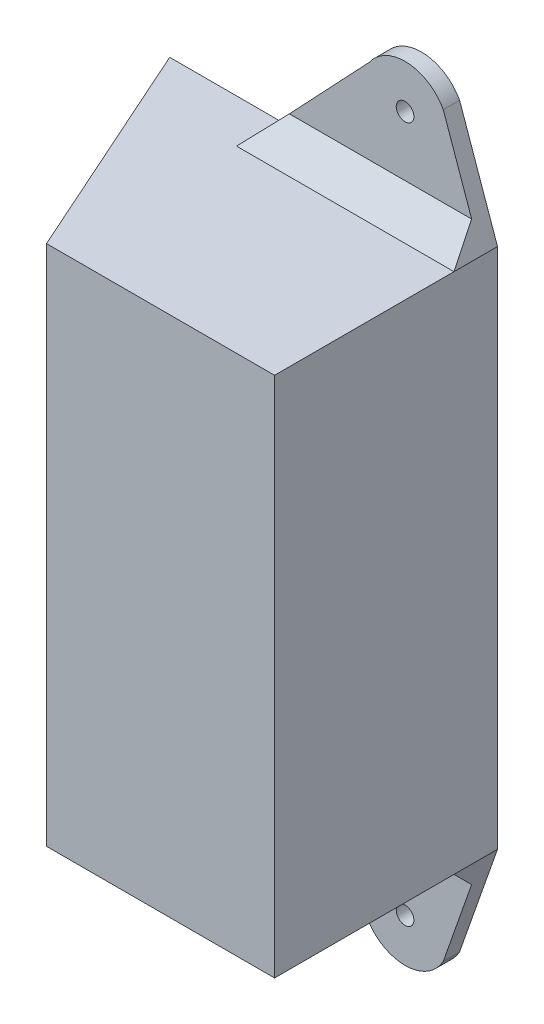
from build123d import *

# Parameters (mm, degrees)
SALIENTE_EXTRUIR1_DEPTH = 38
CROQUIS2_R              = 1.625
SALIENTE_EXTRUIR2_DEPTH = 3
CHAFL_N1_SIZE           = 5
SALIENTE_EXTRUIR3_DEPTH = 3
SALIENTE_EXTRUIR4_DEPTH = 3
CROQUIS6_W              = 40
CROQUIS6_H              = 96
SALIENTE_EXTRUIR5_DEPTH = 3
SALIENTE_EXTRUIR6_DEPTH = 96
SALIENTE_EXTRUIR7_DEPTH = 2


with BuildPart() as part:
    # Croquis1 → Saliente-Extruir1 (new body)
    with BuildSketch(Plane.XY):
        Polygon((0, 45), (37, 45), (37, -45), (0, -45), (0, -48), (40, -48), (40, 48), (0, 48), align=None)
    extrude(amount=SALIENTE_EXTRUIR1_DEPTH)

    # Croquis2 → Saliente-Extruir2 (add)
    with BuildSketch(Plane(origin=(0, 0, 0), x_dir=(-1, 0, 0), z_dir=(0, 0, -1))):
        with BuildLine():
            Line((-40, -48), (-33.026334459, -67.824999879))
            ThreePointArc((-33.026334459, -67.824999879), (-26.445010121, -71.987613285), (-19.442030485, -68.58181578))
            Line((-19.442030485, -68.58181578), (0, -48))
            Line((0, -48), (-40, -48))
        make_face()
        with Locations((-26, -64)):
            Circle(CROQUIS2_R, mode=Mode.SUBTRACT)
        with BuildLine():
            Line((-40, 48), (0, 48))
            Line((0, 48), (-19.442030485, 68.58181578))
            ThreePointArc((-19.442030485, 68.58181578), (-26.445010121, 71.987613285), (-33.026334459, 67.824999879))
            Line((-33.026334459, 67.824999879), (-40, 48))
        make_face()
        with Locations((-26, 64)):
            Circle(CROQUIS2_R, mode=Mode.SUBTRACT)
    extrude(amount=-SALIENTE_EXTRUIR2_DEPTH)

    # Chaflán1
    chafl_n1_edges = [part.edges().sort_by_distance(p)[0] for p in [
        (20, -48, 3),
        (20, 48, 3),
    ]]
    chamfer(chafl_n1_edges, length=CHAFL_N1_SIZE)

    # Croquis3 → Saliente-Extruir3 (add)
    with BuildSketch(Plane.XZ.offset(48)):
        Polygon((0, 38), (-17, 0), (0, 0), align=None)
    extrude(amount=-SALIENTE_EXTRUIR3_DEPTH)

    # Croquis4 → Saliente-Extruir4 (add)
    with BuildSketch(Plane(origin=(0, 48, 0), x_dir=(1, 0, 0), z_dir=(0, 1, 0))):
        Polygon((0, 0), (0, -38), (-17, 0), align=None)
    extrude(amount=-SALIENTE_EXTRUIR4_DEPTH)

    # Croquis6 → Saliente-Extruir5 (add)
    with BuildSketch(Plane.XY.offset(38)):
        with Locations((20, 0)):
            Rectangle(CROQUIS6_W, CROQUIS6_H)
    extrude(amount=SALIENTE_EXTRUIR5_DEPTH)

    # Croquis7 → Saliente-Extruir6 (add)
    with BuildSketch(Plane.XZ.offset(48)):
        Polygon((-17, 0), (0, 38), (0, 41), (-1.944419731, 41), (-20.286524994, 0), align=None)
    extrude(amount=-SALIENTE_EXTRUIR6_DEPTH)

    # Croquis8 → Saliente-Extruir7 (add)
    with BuildSketch(Plane(origin=(-16.903486493, 0, 7.562086062), x_dir=(0.40836606, 0, 0.912818252), z_dir=(-0.912818252, 0, 0.40836606))):
        with BuildLine():
            add(Edge.make_bspline(
                [(5.965671716, 30.36328125), (5.969777422, 30.634302022), (5.97778628, 31.162972825), (6.051447483, 31.933692823), (6.159339503, 32.662226364), (6.326924559, 33.343984113), (6.529341591, 33.984579111), (6.79151938, 34.575666339), (7.088726166, 35.129018553), (7.330384134, 35.463352831), (7.450046716, 35.62890625)],
                knots=[0, 0, 0, 0, 0.000812838, 0.001585575, 0.002320915, 0.003020123, 0.003689655, 0.004333381, 0.004957513, 0.005569711, 0.005569711, 0.005569711, 0.005569711], degree=3))
            add(Edge.make_bspline(
                [(7.450046716, 35.62890625), (7.553673427, 35.756762143), (7.754719282, 36.00481496), (8.078174582, 36.340898549), (8.419904084, 36.61842414), (8.771347852, 36.848802777), (9.13456118, 37.031738976), (9.513179133, 37.154081432), (9.900673914, 37.239339417), (10.164422368, 37.246421297), (10.297702966, 37.25)],
                knots=[0, 0, 0, 0, 0.000493642, 0.000957714, 0.001396364, 0.001811328, 0.002216619, 0.002611904, 0.003002607, 0.003401733, 0.003401733, 0.003401733, 0.003401733], degree=3))
            add(Edge.make_bspline(
                [(10.297702966, 37.25), (10.429822742, 37.244586132), (10.687522929, 37.23402636), (11.056297545, 37.134519745), (11.387218266, 36.966346565), (11.677456504, 36.73904813), (11.920195351, 36.455945202), (12.094779911, 36.1153008), (12.197073919, 35.723276709), (12.209281684, 35.44594681), (12.215671716, 35.30078125)],
                knots=[0, 0, 0, 0, 0.000395767, 0.000771945, 0.00113531, 0.001502581, 0.001871199, 0.002245079, 0.002641135, 0.003076151, 0.003076151, 0.003076151, 0.003076151], degree=3))
            add(Edge.make_bspline(
                [(12.215671716, 35.30078125), (12.211834834, 35.201557757), (12.204352359, 35.008057567), (12.148733947, 34.729162915), (12.058811627, 34.470218823), (11.928050321, 34.232525347), (11.757435691, 34.018106537), (11.555647016, 33.819389361), (11.315754931, 33.641544695), (11.133857418, 33.548213979), (11.039890466, 33.5)],
                knots=[0, 0, 0, 0, 0.000297517, 0.000580201, 0.000849534, 0.001117019, 0.00138973, 0.00166872, 0.001964823, 0.002281253, 0.002281253, 0.002281253, 0.002281253], degree=3))
            add(Edge.make_bspline(
                [(11.039890466, 33.5), (10.91436369, 33.434443546), (10.663995614, 33.303688628), (10.34327864, 33.0213451), (10.065057019, 32.691686878), (9.844623673, 32.298302696), (9.674362764, 31.849036212), (9.551043095, 31.342749802), (9.476603513, 30.779551596), (9.469425304, 30.385659352), (9.465671716, 30.1796875)],
                knots=[0, 0, 0, 0, 0.000423463, 0.000844614, 0.001271737, 0.001712642, 0.002189973, 0.002709151, 0.003272654, 0.003890286, 0.003890286, 0.003890286, 0.003890286], degree=3))
            add(Edge.make_bspline(
                [(9.465671716, 30.1796875), (9.468590461, 29.995985609), (9.474416706, 29.629289488), (9.524035202, 29.083109154), (9.597397863, 28.540445487), (9.702410238, 28.002898303), (9.840791609, 27.468582346), (10.007658096, 26.938704675), (10.207735792, 26.413821778), (10.361159091, 26.07091354), (10.438327966, 25.8984375)],
                knots=[0, 0, 0, 0, 0.000551003, 0.001099883, 0.001644031, 0.002193314, 0.002741875, 0.003299046, 0.003859113, 0.004425896, 0.004425896, 0.004425896, 0.004425896], degree=3))
            add(Edge.make_bspline(
                [(10.438327966, 25.8984375), (10.5206725, 25.729254519), (10.677123914, 25.407813433), (10.934622805, 24.969854511), (11.194905283, 24.5952256), (11.470695314, 24.295443596), (11.742961267, 24.047573089), (12.031337759, 23.877105944), (12.327220813, 23.772883566), (12.527408766, 23.757542292), (12.625827966, 23.75)],
                knots=[0, 0, 0, 0, 0.00056426, 0.001072073, 0.001522987, 0.001929481, 0.002292174, 0.002623123, 0.002928236, 0.003223307, 0.003223307, 0.003223307, 0.003223307], degree=3))
            add(Edge.make_bspline(
                [(12.625827966, 23.75), (12.756404433, 23.752620818), (13.007710327, 23.757664814), (13.365679792, 23.827553873), (13.692820878, 23.9306952), (13.982591123, 24.084324753), (14.238889739, 24.278515986), (14.455041332, 24.51866116), (14.643147362, 24.797021755), (14.729765645, 25.008527307), (14.774265466, 25.1171875)],
                knots=[0, 0, 0, 0, 0.000391113, 0.000752731, 0.001089961, 0.001416711, 0.00173157, 0.002049516, 0.002382121, 0.002733532, 0.002733532, 0.002733532, 0.002733532], degree=3))
            add(Edge.make_bspline(
                [(14.774265466, 25.1171875), (14.805970758, 25.207825433), (14.875669416, 25.40707741), (14.948166421, 25.74581325), (15.01932726, 26.142869369), (15.075397293, 26.602144038), (15.125781228, 27.121830616), (15.168663722, 27.702657595), (15.199664175, 28.344785617), (15.210174324, 28.792936129), (15.215671716, 29.02734375)],
                knots=[0, 0, 0, 0, 0.000287819, 0.000632722, 0.001037315, 0.001498087, 0.002020095, 0.00260371, 0.003245097, 0.003948493, 0.003948493, 0.003948493, 0.003948493], degree=3))
            add(Edge.make_bspline(
                [(15.215671716, 29.02734375), (15.231293463, 29.397904388), (15.261815507, 30.121912251), (15.438500027, 31.174693804), (15.685865109, 32.173488066), (15.938809758, 32.798025083), (16.063327966, 33.10546875)],
                knots=[0, 0, 0, 0, 0.001111601, 0.002171865, 0.003197001, 0.00419094, 0.00419094, 0.00419094, 0.00419094], degree=3))
            add(Edge.make_bspline(
                [(16.063327966, 33.10546875), (16.153977971, 33.297966849), (16.327812467, 33.667109798), (16.648641052, 34.161530677), (16.989330346, 34.586816264), (17.370195276, 34.92638519), (17.776248945, 35.195326159), (18.216003979, 35.37976083), (18.685377302, 35.490563556), (19.008023177, 35.496811184), (19.172702966, 35.5)],
                knots=[0, 0, 0, 0, 0.000637629, 0.001222745, 0.001763913, 0.00226738, 0.002747356, 0.003218217, 0.003691067, 0.004184013, 0.004184013, 0.004184013, 0.004184013], degree=3))
            add(Edge.make_bspline(
                [(19.172702966, 35.5), (19.383133092, 35.489330289), (19.804392211, 35.467970642), (20.425503556, 35.322250941), (21.036092544, 35.109044929), (21.630099528, 34.803685744), (22.206451183, 34.410364119), (22.773711286, 33.940601473), (23.325255341, 33.385998264), (23.851017267, 32.758308671), (24.347088649, 32.087714846), (24.775573283, 31.38050143), (25.147202655, 30.662268595), (25.443423634, 29.922137994), (25.681450327, 29.168237885), (25.84231204, 28.393291847), (25.950175353, 27.603309591), (25.96048539, 27.069371583), (25.965671716, 26.80078125)],
                knots=[0, 0, 0, 0, 0.000630953, 0.001263102, 0.001905559, 0.002567665, 0.003259965, 0.003995181, 0.004774103, 0.005602863, 0.006449799, 0.007273824, 0.008080935, 0.008873047, 0.009662544, 0.01044937, 0.011244942, 0.012050236, 0.012050236, 0.012050236, 0.012050236], degree=3))
            add(Edge.make_bspline(
                [(25.965671716, 26.80078125), (25.958390342, 26.572535522), (25.94292304, 26.087689435), (25.822968219, 25.325926481), (25.645291601, 24.487667488), (25.476274874, 23.911725421), (25.387546716, 23.609375)],
                knots=[0, 0, 0, 0, 0.000684497, 0.001454028, 0.00230906, 0.003253969, 0.003253969, 0.003253969, 0.003253969], degree=3))
            add(Edge.make_bspline(
                [(25.387546716, 23.609375), (25.328971324, 23.423538611), (25.218910095, 23.074358163), (25.024477779, 22.595860821), (24.834222475, 22.185269169), (24.627208362, 21.851830138), (24.417624911, 21.587645796), (24.198917313, 21.396480915), (23.968618102, 21.270664328), (23.805545788, 21.256695034), (23.727390466, 21.25)],
                knots=[0, 0, 0, 0, 0.000584282, 0.001097846, 0.001548607, 0.001939896, 0.002273005, 0.002555608, 0.002808913, 0.003042048, 0.003042048, 0.003042048, 0.003042048], degree=3))
            add(Edge.make_bspline(
                [(23.727390466, 21.25), (23.618730778, 21.256397837), (23.404462582, 21.26901386), (23.09210073, 21.358611728), (22.799926472, 21.50743), (22.629984532, 21.647640693), (22.543796716, 21.71875)],
                knots=[0, 0, 0, 0, 0.000325721, 0.000642296, 0.000967244, 0.001301633, 0.001301633, 0.001301633, 0.001301633], degree=3))
            add(Edge.make_bspline(
                [(22.543796716, 21.71875), (22.454451619, 21.808809898), (22.279307214, 21.985355538), (22.097947988, 22.314141585), (21.983039457, 22.675923308), (21.97156254, 22.931380168), (21.965671716, 23.0625)],
                knots=[0, 0, 0, 0, 0.000378906, 0.000742775, 0.00111469, 0.001506894, 0.001506894, 0.001506894, 0.001506894], degree=3))
            add(Edge.make_bspline(
                [(21.965671716, 23.0625), (21.969341393, 23.177191653), (21.977537807, 23.433361374), (22.029164939, 23.854238637), (22.107188362, 24.350626213), (22.216203362, 24.895732972), (22.323600417, 25.441142593), (22.402600073, 25.939978671), (22.453797135, 26.363528423), (22.461996372, 26.622290166), (22.465671716, 26.73828125)],
                knots=[0, 0, 0, 0, 0.000344105, 0.000768576, 0.001270784, 0.00185149, 0.002436032, 0.00293824, 0.003366594, 0.003714601, 0.003714601, 0.003714601, 0.003714601], degree=3))
            add(Edge.make_bspline(
                [(22.465671716, 26.73828125), (22.454620069, 27.016384253), (22.432662659, 27.568919228), (22.27226995, 28.38403688), (22.026719165, 29.180064167), (21.783534273, 29.681101901), (21.660984216, 29.93359375)],
                knots=[0, 0, 0, 0, 0.000833827, 0.001656646, 0.002484366, 0.003325226, 0.003325226, 0.003325226, 0.003325226], degree=3))
            add(Edge.make_bspline(
                [(21.660984216, 29.93359375), (21.595094092, 30.057017109), (21.469831212, 30.291655696), (21.262214793, 30.611719685), (21.046920458, 30.880550624), (20.833393022, 31.108616174), (20.609413616, 31.283374531), (20.379404891, 31.406298498), (20.145493362, 31.487128452), (19.98581651, 31.495749071), (19.907077966, 31.5)],
                knots=[0, 0, 0, 0, 0.000419627, 0.000797747, 0.001142428, 0.001451836, 0.001733113, 0.001990007, 0.002232131, 0.002467675, 0.002467675, 0.002467675, 0.002467675], degree=3))
            add(Edge.make_bspline(
                [(19.907077966, 31.5), (19.828057076, 31.493900957), (19.671210511, 31.48179512), (19.449468336, 31.386073433), (19.252477758, 31.230410484), (19.080097438, 31.015216645), (18.938410873, 30.738529851), (18.81200715, 30.407943228), (18.71868149, 30.014680862), (18.673342568, 29.732096729), (18.649265466, 29.58203125)],
                knots=[0, 0, 0, 0, 0.000236449, 0.000469322, 0.000711541, 0.000983636, 0.001289473, 0.001640601, 0.002043248, 0.00249921, 0.00249921, 0.00249921, 0.00249921], degree=3))
            add(Edge.make_bspline(
                [(18.649265466, 29.58203125), (18.617725092, 29.022151322), (18.554794602, 27.905058726), (18.495332019, 26.787776171), (18.465671716, 26.23046875)],
                knots=[0, 0, 0, 0, 0.001682302, 0.003356589, 0.003356589, 0.003356589, 0.003356589], degree=3))
            add(Edge.make_bspline(
                [(18.465671716, 26.23046875), (18.444171242, 25.993087481), (18.402176228, 25.529431205), (18.286299144, 24.8566621), (18.139773879, 24.220311391), (17.952672522, 23.623646334), (17.729703599, 23.063751948), (17.466583581, 22.542669129), (17.169354052, 22.056142644), (16.936142973, 21.762158702), (16.821140466, 21.6171875)],
                knots=[0, 0, 0, 0, 0.000714801, 0.001396159, 0.002046148, 0.002672526, 0.003270233, 0.003851963, 0.004422128, 0.004976829, 0.004976829, 0.004976829, 0.004976829], degree=3))
            add(Edge.make_bspline(
                [(16.821140466, 21.6171875), (16.686637362, 21.467781616), (16.420244223, 21.171872441), (15.961798381, 20.793742772), (15.470565281, 20.468772898), (14.937920626, 20.207594973), (14.369431498, 19.997185357), (13.760023308, 19.857517929), (13.115811875, 19.762220663), (12.673072078, 19.754141217), (12.446140466, 19.75)],
                knots=[0, 0, 0, 0, 0.000602374, 0.001193045, 0.001777013, 0.00236573, 0.002968787, 0.003591268, 0.004238162, 0.004918399, 0.004918399, 0.004918399, 0.004918399], degree=3))
            add(Edge.make_bspline(
                [(12.446140466, 19.75), (12.306746719, 19.753436109), (12.031206821, 19.760228274), (11.624135507, 19.801076628), (11.230858099, 19.883004937), (10.848145019, 19.985377378), (10.480768164, 20.124281924), (10.124698141, 20.287671415), (9.786302184, 20.489613804), (9.45567061, 20.715843981), (9.140389702, 20.975533399), (8.833635377, 21.260030292), (8.544779452, 21.579420755), (8.266628538, 21.926649016), (8.005245991, 22.307899596), (7.756502019, 22.718194091), (7.516191679, 23.156668293), (7.371594652, 23.464027605), (7.297702966, 23.62109375)],
                knots=[0, 0, 0, 0, 0.000418261, 0.000826777, 0.001225138, 0.001622213, 0.002014028, 0.002401988, 0.002795919, 0.003194663, 0.003602805, 0.004020116, 0.004448684, 0.004893413, 0.00535392, 0.005834262, 0.006332443, 0.006853074, 0.006853074, 0.006853074, 0.006853074], degree=3))
            add(Edge.make_bspline(
                [(7.297702966, 23.62109375), (7.190208386, 23.86978415), (6.973863715, 24.370300943), (6.707918069, 25.151079656), (6.476275425, 25.954932073), (6.288523274, 26.785765629), (6.145459714, 27.642872024), (6.039610494, 28.526489434), (5.975839384, 29.436549006), (5.969087149, 30.051981534), (5.965671716, 30.36328125)],
                knots=[0, 0, 0, 0, 0.0008125, 0.001635246, 0.002472287, 0.003321373, 0.004188965, 0.005078055, 0.005990355, 0.006924153, 0.006924153, 0.006924153, 0.006924153], degree=3))
        make_face()
        with BuildLine():
            add(Edge.make_bspline(
                [(6.215671716, 2.88671875), (6.226597424, 2.975217121), (6.249586424, 3.161428295), (6.385566207, 3.431290004), (6.596790417, 3.695275544), (6.880472038, 3.95992956), (7.242105085, 4.219474387), (7.674209431, 4.486764788), (8.186421673, 4.749368309), (8.558506826, 4.913461698), (8.754734216, 5)],
                knots=[0, 0, 0, 0, 0.000265883, 0.00055945, 0.000890746, 0.001277602, 0.001719026, 0.002224187, 0.00280074, 0.003444074, 0.003444074, 0.003444074, 0.003444074], degree=3))
            add(Edge.make_bspline(
                [(8.754734216, 5), (9.032127533, 5.119072409), (9.601768262, 5.363593419), (10.502807764, 5.677851461), (11.46039743, 5.978794371), (12.124921619, 6.147742799), (12.465671716, 6.234375)],
                knots=[0, 0, 0, 0, 0.000905349, 0.001859178, 0.002861198, 0.003915755, 0.003915755, 0.003915755, 0.003915755], degree=3))
            add(Edge.make_bspline(
                [(12.465671716, 6.234375), (12.456687675, 6.32032522), (12.437493846, 6.503952369), (12.403892549, 6.797749307), (12.378597431, 7.128830166), (12.352165197, 7.497470419), (12.318074208, 7.903345658), (12.294389465, 8.349079842), (12.25996748, 8.831801529), (12.243646437, 9.166626545), (12.235202966, 9.33984375)],
                knots=[0, 0, 0, 0, 0.000259258, 0.000553889, 0.000887044, 0.001255249, 0.001662699, 0.00210885, 0.002594232, 0.003114482, 0.003114482, 0.003114482, 0.003114482], degree=3))
            add(Edge.make_bspline(
                [(12.235202966, 9.33984375), (12.217001677, 9.657644628), (12.182816847, 10.254523736), (12.115125551, 11.09037255), (12.048326871, 11.808381671), (11.991508361, 12.246218375), (11.965671716, 12.4453125)],
                knots=[0, 0, 0, 0, 0.000954924, 0.001793495, 0.002515676, 0.003117923, 0.003117923, 0.003117923, 0.003117923], degree=3))
            add(Edge.make_bspline(
                [(11.965671716, 12.4453125), (11.826012935, 12.497852353), (11.529501354, 12.609400477), (11.065911535, 12.804672276), (10.549014986, 13.017758366), (9.983144028, 13.261268157), (9.365707131, 13.528669072), (8.703004189, 13.832820156), (7.987691705, 14.154449017), (7.496683741, 14.382290696), (7.243015466, 14.5)],
                knots=[0, 0, 0, 0, 0.000447602, 0.000950311, 0.001508905, 0.002124917, 0.002798391, 0.003527396, 0.004312329, 0.005151264, 0.005151264, 0.005151264, 0.005151264], degree=3))
            add(Edge.make_bspline(
                [(7.243015466, 14.5), (7.16084071, 14.548674139), (7.002096897, 14.642702024), (6.794702375, 14.813810954), (6.6151975, 14.993820184), (6.470329707, 15.190552204), (6.35462851, 15.400232267), (6.272047844, 15.623819874), (6.22420476, 15.862550284), (6.218560156, 16.025824679), (6.215671716, 16.109375)],
                knots=[0, 0, 0, 0, 0.000286118, 0.000552718, 0.000804087, 0.001047061, 0.001283058, 0.001520344, 0.001759361, 0.002009849, 0.002009849, 0.002009849, 0.002009849], degree=3))
            add(Edge.make_bspline(
                [(6.215671716, 16.109375), (6.221481612, 16.228503463), (6.232970077, 16.464067587), (6.331268012, 16.806197336), (6.491562445, 17.127887179), (6.706782468, 17.423407479), (6.969455777, 17.68080029), (7.278638422, 17.865819626), (7.622847275, 17.983188354), (7.864438416, 17.994277534), (7.989109216, 18)],
                knots=[0, 0, 0, 0, 0.00035684, 0.000705613, 0.001058497, 0.001430412, 0.00179787, 0.002153596, 0.002503178, 0.002875934, 0.002875934, 0.002875934, 0.002875934], degree=3))
            add(Edge.make_bspline(
                [(7.989109216, 18), (8.021754972, 17.998128777), (8.096780084, 17.99382841), (8.220147283, 17.96713291), (8.369288315, 17.933299323), (8.542124509, 17.88044471), (8.741422403, 17.814118085), (8.966029364, 17.731427037), (9.216916889, 17.638639685), (9.491095352, 17.527702905), (9.792030163, 17.403021972), (10.118048768, 17.26180796), (10.471661193, 17.111444336), (10.845470059, 16.936585156), (11.247946193, 16.753309675), (11.678636253, 16.560354489), (12.129607322, 16.343470569), (12.439561818, 16.196466749), (12.598484216, 16.12109375)],
                knots=[0, 0, 0, 0, 9.7968e-05, 0.000225147, 0.00037769, 0.00055691, 0.000766905, 0.001007861, 0.001274861, 0.001569362, 0.001895084, 0.002252073, 0.002635224, 0.003047736, 0.003489988, 0.003961982, 0.00446346, 0.004991137, 0.004991137, 0.004991137, 0.004991137], degree=3))
            add(Edge.make_bspline(
                [(12.598484216, 16.12109375), (12.730914756, 16.172734623), (12.979981057, 16.269857246), (13.246917507, 16.27495603), (13.371921716, 16.27734375)],
                knots=[0, 0, 0, 0, 0.000422489, 0.000794589, 0.000794589, 0.000794589, 0.000794589], degree=3))
            add(Edge.make_bspline(
                [(13.371921716, 16.27734375), (13.424706588, 16.269503685), (13.530181082, 16.253837702), (13.679176138, 16.182419458), (13.8171152, 16.076801407), (13.952456261, 15.940656609), (14.066291751, 15.758520764), (14.180253107, 15.54797869), (14.285978145, 15.301178645), (14.342317847, 15.121668109), (14.371921716, 15.02734375)],
                knots=[0, 0, 0, 0, 0.000159344, 0.000318401, 0.000488715, 0.000679323, 0.000890586, 0.001130017, 0.001397759, 0.001694222, 0.001694222, 0.001694222, 0.001694222], degree=3))
            add(Edge.make_bspline(
                [(14.371921716, 15.02734375), (14.923663023, 14.71651878), (16.042378716, 14.086287243), (17.725996316, 13.096246575), (19.440012895, 12.054894345), (20.585238885, 11.331159343), (21.164890466, 10.96484375)],
                knots=[0, 0, 0, 0, 0.001899775, 0.003852002, 0.005859107, 0.00791617, 0.00791617, 0.00791617, 0.00791617], degree=3))
            add(Edge.make_bspline(
                [(21.164890466, 10.96484375), (21.369749384, 10.835306896), (21.766911784, 10.58417227), (22.337087326, 10.208157793), (22.867411561, 9.850677187), (23.365320652, 9.52251155), (23.81737749, 9.203865946), (24.23350764, 8.908446083), (24.606242845, 8.626619244), (24.943328899, 8.369005397), (25.242089127, 8.132944219), (25.495533646, 7.907757531), (25.713945074, 7.708026944), (25.892682018, 7.525712686), (26.034626119, 7.364913027), (26.134732002, 7.218634844), (26.199583859, 7.090937491), (26.210826145, 7.008281888), (26.215671716, 6.97265625)],
                knots=[0, 0, 0, 0, 0.000727119, 0.001409674, 0.00204888, 0.002645834, 0.003198496, 0.003707988, 0.004176738, 0.004600202, 0.004980876, 0.00531858, 0.005617095, 0.005868465, 0.006084548, 0.006258978, 0.006400576, 0.006507838, 0.006507838, 0.006507838, 0.006507838], degree=3))
            add(Edge.make_bspline(
                [(26.215671716, 6.97265625), (26.210861665, 6.85367274), (26.201590584, 6.624339221), (26.1172731, 6.294659081), (25.973927066, 5.999382048), (25.779654454, 5.730128721), (25.522833839, 5.500926288), (25.219154489, 5.293521651), (24.854175051, 5.127871763), (24.589058257, 5.043985163), (24.450046716, 5)],
                knots=[0, 0, 0, 0, 0.000356519, 0.000687169, 0.001012139, 0.001336382, 0.001676405, 0.00203935, 0.002436041, 0.002873332, 0.002873332, 0.002873332, 0.002873332], degree=3))
            add(Edge.make_bspline(
                [(24.450046716, 5), (24.325002369, 4.97679426), (24.05910302, 4.927448638), (23.638988805, 4.844328496), (23.172363366, 4.755640824), (22.662462938, 4.652752169), (22.107179751, 4.545066465), (21.510135084, 4.422220365), (20.867725015, 4.294402175), (20.425255243, 4.203381377), (20.196140466, 4.15625)],
                knots=[0, 0, 0, 0, 0.000381535, 0.000811311, 0.001284758, 0.001806458, 0.002371826, 0.002981626, 0.003635092, 0.004336827, 0.004336827, 0.004336827, 0.004336827], degree=3))
            add(Edge.make_bspline(
                [(20.196140466, 4.15625), (19.871959496, 4.085767146), (19.211867172, 3.942251037), (18.204108402, 3.726534371), (17.165086534, 3.488701376), (16.088997115, 3.247743716), (14.978201905, 2.994318649), (13.833655018, 2.728725154), (12.655501682, 2.450373874), (11.858869548, 2.260548162), (11.453952966, 2.1640625)],
                knots=[0, 0, 0, 0, 0.000995266, 0.002026546, 0.003091714, 0.004192895, 0.005334764, 0.006509714, 0.007717762, 0.008966523, 0.008966523, 0.008966523, 0.008966523], degree=3))
            add(Edge.make_bspline(
                [(11.453952966, 2.1640625), (11.417395542, 2.15397032), (11.333199529, 2.130726853), (11.192905378, 2.082489364), (11.021977963, 2.020841104), (10.819926531, 1.939860605), (10.585360673, 1.84793249), (10.317159347, 1.742948651), (10.021353609, 1.61659301), (9.813314082, 1.527370675), (9.703952966, 1.48046875)],
                knots=[0, 0, 0, 0, 0.000113752, 0.000261983, 0.000444869, 0.000658859, 0.00091492, 0.001200717, 0.001522835, 0.001879824, 0.001879824, 0.001879824, 0.001879824], degree=3))
            add(Edge.make_bspline(
                [(9.703952966, 1.48046875), (9.526483136, 1.407607138), (9.199612309, 1.273407789), (8.735027356, 1.123805994), (8.342109035, 1.024983769), (8.100189095, 1.007670153), (7.993015466, 1)],
                knots=[0, 0, 0, 0, 0.000575228, 0.001059477, 0.001464108, 0.001785942, 0.001785942, 0.001785942, 0.001785942], degree=3))
            add(Edge.make_bspline(
                [(7.993015466, 1), (7.869752312, 1.006143318), (7.62718787, 1.018232499), (7.281405928, 1.132548801), (6.967454441, 1.318128697), (6.696963992, 1.569651701), (6.473623904, 1.864633737), (6.316491338, 2.188614661), (6.219271283, 2.532101617), (6.216880925, 2.767591613), (6.215671716, 2.88671875)],
                knots=[0, 0, 0, 0, 0.000368867, 0.000725877, 0.001079603, 0.001455619, 0.001826713, 0.002183103, 0.002530847, 0.002886852, 0.002886852, 0.002886852, 0.002886852], degree=3))
        make_face()
        with BuildLine():
            add(Edge.make_bspline(
                [(19.895359216, 7.8984375), (19.745605766, 7.988258362), (19.433076827, 8.175710596), (18.945033459, 8.469071988), (18.417052175, 8.783578064), (17.854663916, 9.130503853), (17.249470086, 9.496002157), (16.605799343, 9.885899979), (15.923765286, 10.301690692), (15.456530903, 10.587196724), (15.215671716, 10.734375)],
                knots=[0, 0, 0, 0, 0.000523875, 0.001093303, 0.001708287, 0.002367506, 0.003075616, 0.003829279, 0.004625158, 0.005471958, 0.005471958, 0.005471958, 0.005471958], degree=3))
            add(Edge.make_bspline(
                [(15.215671716, 10.734375), (15.230375772, 10.621145338), (15.263115846, 10.369027996), (15.308106658, 9.94874934), (15.334110884, 9.445354944), (15.353621863, 9.082016775), (15.364109216, 8.88671875)],
                knots=[0, 0, 0, 0, 0.000342549, 0.000762721, 0.001267595, 0.001854366, 0.001854366, 0.001854366, 0.001854366], degree=3))
            add(Edge.make_bspline(
                [(15.364109216, 8.88671875), (15.369241314, 8.768226057), (15.378998972, 8.542935892), (15.394051559, 8.222588352), (15.411360667, 7.936282975), (15.421561952, 7.683536105), (15.433617637, 7.464799956), (15.444485089, 7.281130774), (15.457625224, 7.131588181), (15.463209354, 7.042979075), (15.465671716, 7.00390625)],
                knots=[0, 0, 0, 0, 0.000355812, 0.000676505, 0.000962089, 0.001216266, 0.00143533, 0.001619297, 0.001768196, 0.001885644, 0.001885644, 0.001885644, 0.001885644], degree=3))
            add(Edge.make_bspline(
                [(15.465671716, 7.00390625), (15.612758382, 7.032804712), (15.917210356, 7.092621105), (16.392023049, 7.180663408), (16.898096232, 7.283211398), (17.435454526, 7.393254039), (18.005378216, 7.504656446), (18.605729873, 7.632970732), (19.241210094, 7.757857601), (19.674142595, 7.850896948), (19.895359216, 7.8984375)],
                knots=[0, 0, 0, 0, 0.000449694, 0.000930813, 0.001448683, 0.001998729, 0.002576352, 0.003190765, 0.003840401, 0.00451919, 0.00451919, 0.00451919, 0.00451919], degree=3))
        make_face(mode=Mode.SUBTRACT)
        with BuildLine():
            add(Edge.make_bspline(
                [(17.160984216, -7.3046875), (16.973520929, -7.255069257), (16.575400345, -7.149693722), (15.945390165, -6.98612304), (15.247129631, -6.810366956), (14.481497803, -6.61898635), (13.648432512, -6.412151192), (12.747055272, -6.193457667), (11.779523137, -5.959431869), (11.111511151, -5.798152029), (10.766452966, -5.71484375)],
                knots=[0, 0, 0, 0, 0.000581756, 0.00123549, 0.001952678, 0.002741866, 0.003603059, 0.004527744, 0.005524442, 0.006589359, 0.006589359, 0.006589359, 0.006589359], degree=3))
            add(Edge.make_bspline(
                [(10.766452966, -5.71484375), (10.274299962, -5.636500177), (9.29273476, -5.480249326), (8.310757912, -5.326606771), (7.821140466, -5.25)],
                knots=[0, 0, 0, 0, 0.001495048, 0.00298177, 0.00298177, 0.00298177, 0.00298177], degree=3))
            add(Edge.make_bspline(
                [(7.821140466, -5.25), (7.675438102, -5.200980134), (7.396629912, -5.107178359), (7.016016134, -4.924768568), (6.692596355, -4.711790884), (6.425978893, -4.468502001), (6.218845611, -4.191249582), (6.073589529, -3.884241274), (5.977699503, -3.549993728), (5.969757349, -3.31579162), (5.965671716, -3.1953125)],
                knots=[0, 0, 0, 0, 0.000460888, 0.00088193, 0.001262203, 0.001618786, 0.001959415, 0.002293119, 0.002633322, 0.002993736, 0.002993736, 0.002993736, 0.002993736], degree=3))
            add(Edge.make_bspline(
                [(5.965671716, -3.1953125), (5.972196057, -3.045866032), (5.984727272, -2.758826237), (6.108181114, -2.355436402), (6.298073698, -1.994297617), (6.487605108, -1.805714844), (6.582859216, -1.7109375)],
                knots=[0, 0, 0, 0, 0.000447022, 0.00085859, 0.001255454, 0.00165643, 0.00165643, 0.00165643, 0.00165643], degree=3))
            add(Edge.make_bspline(
                [(6.582859216, -1.7109375), (6.671444285, -1.639282875), (6.846813701, -1.497430193), (7.153345503, -1.355030059), (7.481149804, -1.263246418), (7.708510797, -1.254488797), (7.825046716, -1.25)],
                knots=[0, 0, 0, 0, 0.000340629, 0.000674333, 0.001005973, 0.001354703, 0.001354703, 0.001354703, 0.001354703], degree=3))
            add(Edge.make_bspline(
                [(7.825046716, -1.25), (8.006111963, -1.253456181), (8.379119386, -1.260576162), (8.953818833, -1.306033577), (9.558352421, -1.376540739), (10.191951489, -1.473768439), (10.851957556, -1.604444703), (11.540739723, -1.761849026), (12.260513787, -1.944109373), (12.747364628, -2.086941354), (12.996921716, -2.16015625)],
                knots=[0, 0, 0, 0, 0.000543194, 0.001119018, 0.001728555, 0.002368859, 0.003041483, 0.003746515, 0.004488343, 0.005268508, 0.005268508, 0.005268508, 0.005268508], degree=3))
            add(Edge.make_bspline(
                [(12.996921716, -2.16015625), (13.181883246, -2.214622286), (13.54151622, -2.320524214), (14.064090551, -2.478384709), (14.556125227, -2.620336029), (15.014378259, -2.760432481), (15.442855277, -2.882000165), (15.838598577, -3.00263921), (16.204509391, -3.104858359), (16.536760196, -3.204936444), (16.838303366, -3.289556309), (17.106184446, -3.367549513), (17.342394711, -3.436811602), (17.548956567, -3.486361942), (17.720772322, -3.542994331), (17.864348096, -3.574593342), (17.974762093, -3.602956637), (18.03727918, -3.618516658), (18.063327966, -3.625)],
                knots=[0, 0, 0, 0, 0.000578442, 0.001124702, 0.001637672, 0.002114715, 0.002562215, 0.002973782, 0.003355817, 0.003701911, 0.004014729, 0.004295354, 0.004538955, 0.004753087, 0.004932307, 0.005081053, 0.005193794, 0.005274323, 0.005274323, 0.005274323, 0.005274323], degree=3))
            add(Edge.make_bspline(
                [(18.063327966, -3.625), (18.735324481, -3.753279229), (20.079804189, -4.00993059), (21.422824657, -4.274111654), (22.094577966, -4.40625)],
                knots=[0, 0, 0, 0, 0.002052388, 0.004106262, 0.004106262, 0.004106262, 0.004106262], degree=3))
            add(Edge.make_bspline(
                [(22.094577966, -4.40625), (22.316341669, -4.454000675), (22.741896837, -4.545632201), (23.347531058, -4.704907348), (23.898321666, -4.858536601), (24.390515837, -5.01659413), (24.822071664, -5.182662613), (25.200315288, -5.343864622), (25.519501567, -5.513479144), (25.785667113, -5.689920702), (26.008093042, -5.871917455), (26.197989493, -6.063605303), (26.354649225, -6.270372066), (26.489730274, -6.484130248), (26.59227298, -6.712962764), (26.661790369, -6.95378356), (26.706306996, -7.205400328), (26.712515963, -7.377415695), (26.715671716, -7.46484375)],
                knots=[0, 0, 0, 0, 0.00068045, 0.001305755, 0.001878271, 0.00239586, 0.002855804, 0.003265122, 0.003628634, 0.003938486, 0.004221575, 0.004489516, 0.004745785, 0.004998366, 0.005246651, 0.00549509, 0.005748755, 0.00601094, 0.00601094, 0.00601094, 0.00601094], degree=3))
            add(Edge.make_bspline(
                [(26.715671716, -7.46484375), (26.711796089, -7.562760339), (26.704239745, -7.753669178), (26.648857196, -8.030465936), (26.555718324, -8.287215096), (26.418504471, -8.52181934), (26.246910909, -8.737314742), (26.034089186, -8.930338406), (25.789097432, -9.107708139), (25.603856047, -9.201691689), (25.508640466, -9.25)],
                knots=[0, 0, 0, 0, 0.000293619, 0.000572472, 0.000843133, 0.001109131, 0.001384265, 0.00166622, 0.001968645, 0.002288505, 0.002288505, 0.002288505, 0.002288505], degree=3))
            add(Edge.make_bspline(
                [(25.508640466, -9.25), (25.401159939, -9.297082502), (25.166135601, -9.40003635), (24.766536009, -9.533442211), (24.296416555, -9.673420286), (23.749906443, -9.812978294), (23.129723787, -9.956286571), (22.43465384, -10.105233042), (21.664466199, -10.252165078), (21.125933031, -10.34824226), (20.844577966, -10.3984375)],
                knots=[0, 0, 0, 0, 0.000351866, 0.000769415, 0.001262547, 0.001823431, 0.002461119, 0.0031721, 0.003955817, 0.004813209, 0.004813209, 0.004813209, 0.004813209], degree=3))
            add(Edge.make_bspline(
                [(20.844577966, -10.3984375), (20.263025478, -10.503704473), (19.07368117, -10.718988009), (17.265863312, -11.128125369), (15.389503202, -11.598231733), (14.123549057, -11.95992073), (13.477390466, -12.14453125)],
                knots=[0, 0, 0, 0, 0.001772818, 0.003625624, 0.005559281, 0.007575186, 0.007575186, 0.007575186, 0.007575186], degree=3))
            add(Edge.make_bspline(
                [(13.477390466, -12.14453125), (14.143975898, -12.39961231), (15.501708562, -12.919173451), (17.601897345, -13.64094243), (19.793109707, -14.34298507), (21.292665973, -14.77587524), (22.055515466, -14.99609375)],
                knots=[0, 0, 0, 0, 0.002141031, 0.004360954, 0.006661207, 0.009043088, 0.009043088, 0.009043088, 0.009043088], degree=3))
            Line((22.055515466, -14.99609375), (25.082859216, -15.75))
            add(Edge.make_bspline(
                [(25.082859216, -15.75), (25.231367937, -15.809421132), (25.515225417, -15.922997846), (25.901347269, -16.134615766), (26.22753697, -16.369767785), (26.503006753, -16.623743049), (26.705230165, -16.914537493), (26.859710346, -17.22217054), (26.946533532, -17.557878907), (26.959208349, -17.788597759), (26.965671716, -17.90625)],
                knots=[0, 0, 0, 0, 0.000479579, 0.00091666, 0.001316722, 0.001684179, 0.002034285, 0.002373207, 0.002712399, 0.003065348, 0.003065348, 0.003065348, 0.003065348], degree=3))
            add(Edge.make_bspline(
                [(26.965671716, -17.90625), (26.95883865, -18.020338494), (26.945285097, -18.246635806), (26.83821832, -18.572511345), (26.668324494, -18.876299474), (26.419085635, -19.148659348), (26.109848573, -19.403014293), (25.728579702, -19.627800615), (25.282994027, -19.831785524), (24.957736285, -19.941869992), (24.785984216, -20)],
                knots=[0, 0, 0, 0, 0.000341657, 0.000677686, 0.001018784, 0.001378541, 0.001778164, 0.002216291, 0.002702192, 0.003245849, 0.003245849, 0.003245849, 0.003245849], degree=3))
            add(Edge.make_bspline(
                [(24.785984216, -20), (24.704168772, -20.025508127), (24.527361512, -20.080632462), (24.234640265, -20.152834538), (23.896998436, -20.233059479), (23.507186778, -20.302664114), (23.073667494, -20.388440925), (22.589512351, -20.463247954), (22.06002843, -20.547025585), (21.689727641, -20.598301811), (21.496921716, -20.625)],
                knots=[0, 0, 0, 0, 0.000257042, 0.00055548, 0.000904188, 0.001297965, 0.001743089, 0.002229868, 0.002767414, 0.00335133, 0.00335133, 0.00335133, 0.00335133], degree=3))
            add(Edge.make_bspline(
                [(21.496921716, -20.625), (21.038378187, -20.690005841), (20.137279341, -20.817750938), (18.813107291, -21.029888094), (17.538771101, -21.249953373), (16.315795167, -21.491561833), (15.140994827, -21.733465547), (14.0172453, -21.996456902), (12.944544111, -22.273129938), (12.247872163, -22.470068778), (11.907077966, -22.56640625)],
                knots=[0, 0, 0, 0, 0.001389357, 0.002730271, 0.004023027, 0.005268686, 0.006469945, 0.007621183, 0.008730627, 0.009793048, 0.009793048, 0.009793048, 0.009793048], degree=3))
            add(Edge.make_bspline(
                [(11.907077966, -22.56640625), (11.743107352, -22.614900366), (11.424603724, -22.709097439), (10.95914222, -22.841081785), (10.522726066, -22.965317335), (10.117172451, -23.083641504), (9.739225041, -23.189219208), (9.39172512, -23.286142538), (9.071380413, -23.373291976), (8.78059593, -23.449843695), (8.519582321, -23.521531948), (8.287384458, -23.579834415), (8.084185504, -23.630277438), (7.909107353, -23.675025347), (7.762522505, -23.704476924), (7.645618282, -23.728817896), (7.558664964, -23.74680055), (7.508686381, -23.749099483), (7.489109216, -23.75)],
                knots=[0, 0, 0, 0, 0.00051297, 0.000996414, 0.001451421, 0.001874236, 0.002263785, 0.002628659, 0.002956528, 0.003259734, 0.003530734, 0.003768534, 0.003977911, 0.004158867, 0.004310559, 0.004426239, 0.004517431, 0.004576155, 0.004576155, 0.004576155, 0.004576155], degree=3))
            add(Edge.make_bspline(
                [(7.489109216, -23.75), (7.364429419, -23.742682388), (7.120054172, -23.728339702), (6.770218953, -23.608145888), (6.450283431, -23.415440146), (6.27699849, -23.233648458), (6.188327966, -23.140625)],
                knots=[0, 0, 0, 0, 0.000373144, 0.000731371, 0.00109783, 0.001481857, 0.001481857, 0.001481857, 0.001481857], degree=3))
            add(Edge.make_bspline(
                [(6.188327966, -23.140625), (6.115799588, -23.043901328), (5.97394354, -22.854722439), (5.823834571, -22.536963831), (5.734745845, -22.201449088), (5.72209023, -21.971892402), (5.715671716, -21.85546875)],
                knots=[0, 0, 0, 0, 0.000361935, 0.000707897, 0.001047089, 0.001396147, 0.001396147, 0.001396147, 0.001396147], degree=3))
            add(Edge.make_bspline(
                [(5.715671716, -21.85546875), (5.721044533, -21.740114256), (5.731629854, -21.512847225), (5.835333334, -21.18628251), (5.998122741, -20.883965521), (6.227759438, -20.606367429), (6.519187141, -20.351932863), (6.877675842, -20.127313009), (7.293930454, -19.917528581), (7.60095708, -19.807767697), (7.762546716, -19.75)],
                knots=[0, 0, 0, 0, 0.000345168, 0.000680036, 0.001017356, 0.00136998, 0.001754721, 0.002172964, 0.002635899, 0.00315025, 0.00315025, 0.00315025, 0.00315025], degree=3))
            Line((7.762546716, -19.75), (10.934421716, -18.99609375))
            add(Edge.make_bspline(
                [(10.934421716, -18.99609375), (11.141149747, -18.940201903), (11.575332635, -18.822814419), (12.263428485, -18.663508048), (13.013376613, -18.488070569), (13.829513201, -18.31922725), (14.708347629, -18.142995145), (15.651122318, -17.963431701), (16.658950121, -17.779735305), (17.353594252, -17.659600138), (17.711765466, -17.59765625)],
                knots=[0, 0, 0, 0, 0.000642397, 0.001349202, 0.002118644, 0.002952946, 0.003849258, 0.004807659, 0.005832058, 0.006922518, 0.006922518, 0.006922518, 0.006922518], degree=3))
            add(Edge.make_bspline(
                [(17.711765466, -17.59765625), (17.554158422, -17.543126478), (17.21908374, -17.427195453), (16.685135273, -17.238629404), (16.090273864, -17.024536), (15.432070724, -16.784459574), (14.709568421, -16.524588195), (13.926365046, -16.235031688), (13.080483031, -15.921259614), (12.495657763, -15.705626455), (12.192234216, -15.59375)],
                knots=[0, 0, 0, 0, 0.00050032, 0.001063688, 0.001698787, 0.002396957, 0.003165546, 0.004002223, 0.004901984, 0.005872158, 0.005872158, 0.005872158, 0.005872158], degree=3))
            Line((12.192234216, -15.59375), (9.782077966, -14.78515625))
            add(Edge.make_bspline(
                [(9.782077966, -14.78515625), (9.553325944, -14.704126), (9.114365161, -14.548634034), (8.496758599, -14.288249189), (7.939410042, -14.030117971), (7.597498744, -13.840459133), (7.434421716, -13.75)],
                knots=[0, 0, 0, 0, 0.000727874, 0.001396744, 0.002010075, 0.002569365, 0.002569365, 0.002569365, 0.002569365], degree=3))
            add(Edge.make_bspline(
                [(7.434421716, -13.75), (7.337871299, -13.692309888), (7.151321324, -13.580843885), (6.903785307, -13.382299091), (6.688842159, -13.171883481), (6.516180627, -12.939382381), (6.380890758, -12.69100757), (6.287321759, -12.424468478), (6.226146734, -12.142090883), (6.219203865, -11.946938847), (6.215671716, -11.84765625)],
                knots=[0, 0, 0, 0, 0.000337048, 0.000651229, 0.000949539, 0.00123704, 0.001516685, 0.001794688, 0.002081977, 0.002379494, 0.002379494, 0.002379494, 0.002379494], degree=3))
            add(Edge.make_bspline(
                [(6.215671716, -11.84765625), (6.220258813, -11.749613855), (6.229237616, -11.557705274), (6.297832673, -11.278469255), (6.412864946, -11.016834447), (6.575388547, -10.773759692), (6.781489694, -10.547751169), (7.036507436, -10.344953968), (7.333440655, -10.15656863), (7.554193889, -10.053504945), (7.668796716, -10)],
                knots=[0, 0, 0, 0, 0.000293905, 0.00057529, 0.000856893, 0.001147246, 0.001448635, 0.001770753, 0.002121881, 0.002500968, 0.002500968, 0.002500968, 0.002500968], degree=3))
            Line((7.668796716, -10), (10.110202966, -9.23046875))
            add(Edge.make_bspline(
                [(10.110202966, -9.23046875), (10.675848728, -9.053466163), (11.817775422, -8.696133018), (13.559422841, -8.202212866), (15.344063854, -7.736184915), (16.551046344, -7.449540638), (17.160984216, -7.3046875)],
                knots=[0, 0, 0, 0, 0.001778013, 0.003589456, 0.005430361, 0.007311021, 0.007311021, 0.007311021, 0.007311021], degree=3))
        make_face()
        with BuildLine():
            add(Edge.make_bspline(
                [(22.465671716, -36.74609375), (22.466647517, -36.680979777), (22.468931941, -36.528543122), (22.482144043, -36.265522019), (22.501720125, -35.933488135), (22.529431958, -35.531151947), (22.564754173, -35.058503645), (22.607689541, -34.516828303), (22.65874041, -33.906169802), (22.696015389, -33.47655177), (22.715671716, -33.25)],
                knots=[0, 0, 0, 0, 0.000195352, 0.000457333, 0.000789938, 0.00119321, 0.001667171, 0.002211838, 0.002823325, 0.003505533, 0.003505533, 0.003505533, 0.003505533], degree=3))
            add(Edge.make_bspline(
                [(22.715671716, -33.25), (22.503502282, -33.23085866), (22.061258466, -33.190960646), (21.372067931, -33.147402066), (20.632745176, -33.10105374), (19.843326646, -33.073954435), (19.003629217, -33.043053569), (18.114120254, -33.031293193), (17.174047855, -33.01724191), (16.53078295, -33.016174045), (16.200046716, -33.015625)],
                knots=[0, 0, 0, 0, 0.000639063, 0.001332056, 0.002071587, 0.002861268, 0.003701557, 0.004592319, 0.005529892, 0.006522087, 0.006522087, 0.006522087, 0.006522087], degree=3))
            Line((16.200046716, -33.015625), (10.215671716, -33))
            add(Edge.make_bspline(
                [(10.215671716, -33), (10.228035022, -33.600239385), (10.253001218, -34.812349911), (10.254152866, -36.024717729), (10.254734216, -36.63671875)],
                knots=[0, 0, 0, 0, 0.001801052, 0.003637007, 0.003637007, 0.003637007, 0.003637007], degree=3))
            add(Edge.make_bspline(
                [(10.254734216, -36.63671875), (10.249718876, -36.766378748), (10.240035509, -37.01671975), (10.136274589, -37.374852335), (9.972834821, -37.700200465), (9.73967502, -37.978149817), (9.46913913, -38.210815522), (9.16214986, -38.375798353), (8.829852398, -38.485898172), (8.596783321, -38.495223151), (8.477390466, -38.5)],
                knots=[0, 0, 0, 0, 0.000387979, 0.000749091, 0.001108975, 0.001472592, 0.001830201, 0.002172817, 0.002512571, 0.002869411, 0.002869411, 0.002869411, 0.002869411], degree=3))
            add(Edge.make_bspline(
                [(8.477390466, -38.5), (8.359506536, -38.492974703), (8.128646396, -38.479216584), (7.794844901, -38.377720532), (7.489952275, -38.206982352), (7.22267868, -37.97000552), (6.993105167, -37.688053109), (6.834029867, -37.35704936), (6.730637206, -36.994467238), (6.720760789, -36.740327104), (6.715671716, -36.609375)],
                knots=[0, 0, 0, 0, 0.000353316, 0.000691923, 0.001036426, 0.001393608, 0.001757812, 0.002119431, 0.00248807, 0.002879943, 0.002879943, 0.002879943, 0.002879943], degree=3))
            add(Edge.make_bspline(
                [(6.715671716, -36.609375), (6.71622483, -36.466141383), (6.71745684, -36.147101765), (6.70594155, -35.622419061), (6.701986098, -35.002528342), (6.682259262, -34.320375217), (6.674918523, -33.637984894), (6.659242048, -33.01958917), (6.657893017, -32.49608512), (6.654638794, -32.178383465), (6.653171716, -32.03515625)],
                knots=[0, 0, 0, 0, 0.000429687, 0.000957089, 0.001574326, 0.002289341, 0.00300428, 0.003621579, 0.004145031, 0.004574736, 0.004574736, 0.004574736, 0.004574736], degree=3))
            add(Edge.make_bspline(
                [(6.653171716, -32.03515625), (6.651949161, -31.955731873), (6.649363351, -31.78774246), (6.643553951, -31.520539724), (6.620597749, -31.225250714), (6.599671308, -30.902040159), (6.565492848, -30.552122174), (6.533404766, -30.172639441), (6.483806501, -29.765625077), (6.434617597, -29.338524069), (6.383559035, -28.913056708), (6.341972929, -28.505209212), (6.301356992, -28.12657862), (6.270384184, -27.774953081), (6.246054235, -27.450730719), (6.232059692, -27.154981839), (6.218062128, -26.888144964), (6.216438934, -26.720068103), (6.215671716, -26.640625)],
                knots=[0, 0, 0, 0, 0.000238313, 0.000504053, 0.00080157, 0.001126635, 0.001475693, 0.001856226, 0.002269052, 0.00270561, 0.003146047, 0.003554563, 0.003935478, 0.004288426, 0.004613491, 0.004910777, 0.00517666, 0.005414974, 0.005414974, 0.005414974, 0.005414974], degree=3))
            add(Edge.make_bspline(
                [(6.215671716, -26.640625), (6.222295287, -26.509738224), (6.235162266, -26.255476992), (6.339372985, -25.891249335), (6.5154383, -25.564995467), (6.754214267, -25.280107497), (7.042469818, -25.048526078), (7.361500904, -24.870012586), (7.715201861, -24.771303535), (7.958595169, -24.757200355), (8.082859216, -24.75)],
                knots=[0, 0, 0, 0, 0.000392204, 0.000761897, 0.001125409, 0.001497016, 0.001869157, 0.002229232, 0.002586585, 0.00295934, 0.00295934, 0.00295934, 0.00295934], degree=3))
            add(Edge.make_bspline(
                [(8.082859216, -24.75), (8.208685157, -24.756354104), (8.455879833, -24.768837226), (8.809148044, -24.879737285), (9.135150222, -25.054789353), (9.419296205, -25.302264523), (9.663388309, -25.596858143), (9.842645952, -25.937937826), (9.945942646, -26.318293172), (9.958969191, -26.582703449), (9.965671716, -26.71875)],
                knots=[0, 0, 0, 0, 0.000376644, 0.000739947, 0.001100021, 0.001479652, 0.001862783, 0.002241931, 0.002626672, 0.00303444, 0.00303444, 0.00303444, 0.00303444], degree=3))
            add(Edge.make_bspline(
                [(9.965671716, -26.71875), (9.965671716, -26.891927083), (9.965671716, -27.263020833), (9.965671716, -27.858072917), (9.965671716, -28.528645833), (9.965671716, -29.001302083), (9.965671716, -29.25)],
                knots=[0, 0, 0, 0, 0.000519531, 0.001113281, 0.001785156, 0.00253125, 0.00253125, 0.00253125, 0.00253125], degree=3))
            add(Edge.make_bspline(
                [(9.965671716, -29.25), (10.11280255, -29.247034639), (10.435686456, -29.240527049), (10.965675489, -29.23841157), (11.585459938, -29.233979079), (12.296400218, -29.230233321), (13.098483495, -29.226566155), (13.990405948, -29.221451685), (14.973484939, -29.223003778), (15.658380298, -29.222775564), (16.016452966, -29.22265625)],
                knots=[0, 0, 0, 0, 0.000441475, 0.000968834, 0.00158994, 0.002300888, 0.003101679, 0.003996218, 0.004976687, 0.006050906, 0.006050906, 0.006050906, 0.006050906], degree=3))
            add(Edge.make_bspline(
                [(16.016452966, -29.22265625), (16.616767092, -29.224804867), (17.803332601, -29.229051769), (19.561326522, -29.288507222), (21.278166921, -29.369731915), (22.407252086, -29.456892415), (22.965671716, -29.5)],
                knots=[0, 0, 0, 0, 0.001800849, 0.003559512, 0.005276508, 0.006956658, 0.006956658, 0.006956658, 0.006956658], degree=3))
            Line((22.965671716, -29.5), (22.965671716, -26.62109375))
            add(Edge.make_bspline(
                [(22.965671716, -26.62109375), (22.971518916, -26.49292791), (22.9828326, -26.244941241), (23.075065084, -25.889061202), (23.229888033, -25.566288409), (23.444277579, -25.284104034), (23.70219109, -25.046969553), (23.996536414, -24.871778898), (24.32643934, -24.77017676), (24.554814651, -24.756869345), (24.672702966, -24.75)],
                knots=[0, 0, 0, 0, 0.000384086, 0.000743164, 0.001094335, 0.001451367, 0.001799791, 0.002139455, 0.002470589, 0.002823905, 0.002823905, 0.002823905, 0.002823905], degree=3))
            add(Edge.make_bspline(
                [(24.672702966, -24.75), (24.790676742, -24.75525259), (25.020580931, -24.765488699), (25.345493485, -24.867061535), (25.638983784, -25.029758539), (25.795793898, -25.185921323), (25.875827966, -25.265625)],
                knots=[0, 0, 0, 0, 0.000352949, 0.000687817, 0.001011471, 0.001348858, 0.001348858, 0.001348858, 0.001348858], degree=3))
            add(Edge.make_bspline(
                [(25.875827966, -25.265625), (25.94268175, -25.348175009), (26.075290613, -25.511918362), (26.221446489, -25.796941123), (26.320142752, -26.108982123), (26.349210306, -26.32875773), (26.364109216, -26.44140625)],
                knots=[0, 0, 0, 0, 0.00031797, 0.000630714, 0.000954391, 0.001294751, 0.001294751, 0.001294751, 0.001294751], degree=3))
            add(Edge.make_bspline(
                [(26.364109216, -26.44140625), (26.372451416, -26.544236058), (26.390600122, -26.76794537), (26.407832399, -27.131482706), (26.428315136, -27.546742718), (26.44470464, -28.014208222), (26.449899749, -28.533861213), (26.457920511, -29.106765262), (26.46786779, -29.731741895), (26.466422529, -30.165360254), (26.465671716, -30.390625)],
                knots=[0, 0, 0, 0, 0.000309483, 0.000673288, 0.001091713, 0.00155682, 0.00207641, 0.002650681, 0.00327573, 0.003951511, 0.003951511, 0.003951511, 0.003951511], degree=3))
            add(Edge.make_bspline(
                [(26.465671716, -30.390625), (26.464068122, -30.60939394), (26.460755097, -31.061370363), (26.435744463, -31.762013077), (26.396578831, -32.508201822), (26.341382335, -33.30123637), (26.271038608, -34.139858479), (26.184380985, -35.023970954), (26.083357572, -35.952483787), (26.005503031, -36.586027635), (25.965671716, -36.91015625)],
                knots=[0, 0, 0, 0, 0.000656297, 0.001355908, 0.002103024, 0.002897876, 0.003740658, 0.004627643, 0.005562862, 0.006542552, 0.006542552, 0.006542552, 0.006542552], degree=3))
            add(Edge.make_bspline(
                [(25.965671716, -36.91015625), (25.945175529, -37.034899937), (25.905935112, -37.273724574), (25.782463024, -37.600474033), (25.622438421, -37.88003421), (25.417777751, -38.110908934), (25.166608885, -38.289293686), (24.871982217, -38.413753318), (24.537166354, -38.489440863), (24.300736177, -38.496364866), (24.176609216, -38.5)],
                knots=[0, 0, 0, 0, 0.000378443, 0.000724537, 0.001041426, 0.001340196, 0.001642622, 0.001957554, 0.002293968, 0.002665801, 0.002665801, 0.002665801, 0.002665801], degree=3))
            add(Edge.make_bspline(
                [(24.176609216, -38.5), (24.045505769, -38.492703191), (23.791050243, -38.478540991), (23.431322101, -38.362455358), (23.113382386, -38.1665547), (22.950972575, -37.981329635), (22.868015466, -37.88671875)],
                knots=[0, 0, 0, 0, 0.000392573, 0.000761936, 0.001121757, 0.001497448, 0.001497448, 0.001497448, 0.001497448], degree=3))
            add(Edge.make_bspline(
                [(22.868015466, -37.88671875), (22.806051369, -37.801454363), (22.684296845, -37.633916624), (22.561094367, -37.350301337), (22.476422422, -37.054405681), (22.469279673, -36.849563813), (22.465671716, -36.74609375)],
                knots=[0, 0, 0, 0, 0.000315271, 0.000619482, 0.000922689, 0.001232171, 0.001232171, 0.001232171, 0.001232171], degree=3))
        make_face()
    extrude(amount=SALIENTE_EXTRUIR7_DEPTH)


solid = part.part
